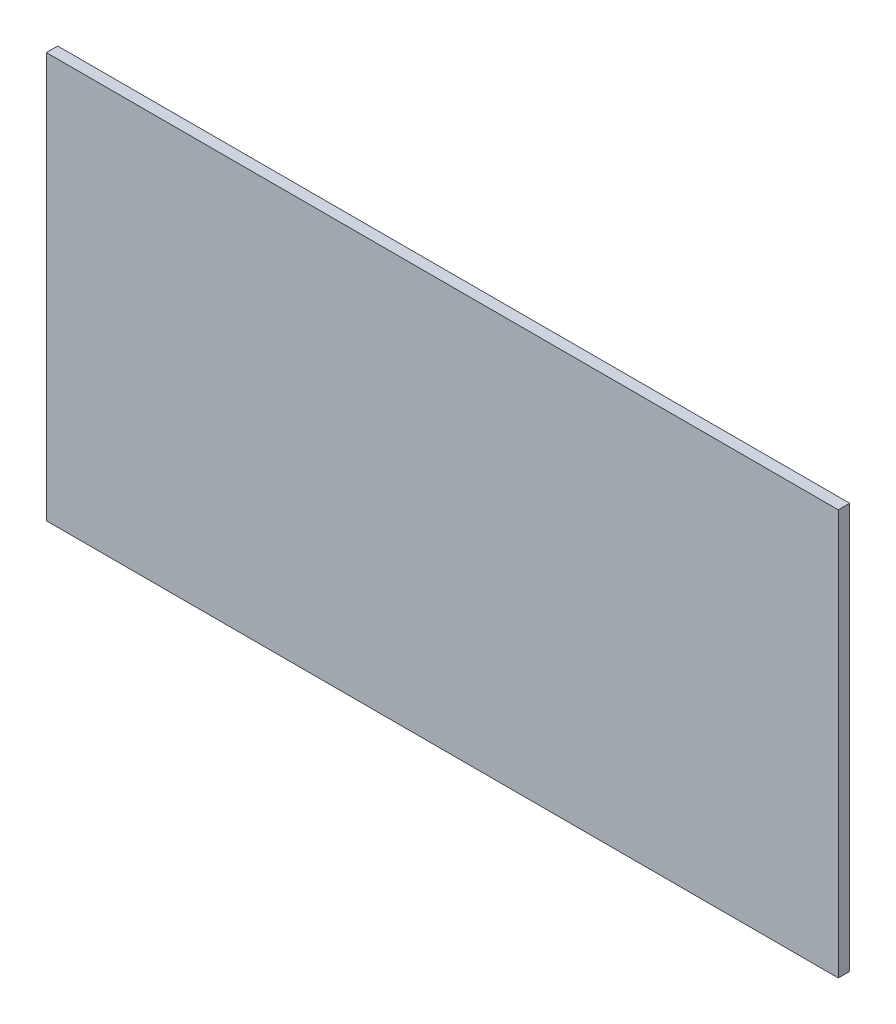
from build123d import *

# Parameters (mm, degrees)
SKETCH1_W           = 209
SKETCH1_H           = 107
BOSS_EXTRUDE1_DEPTH = 3


with BuildPart() as part:
    # Sketch1 → Boss-Extrude1 (new body)
    with BuildSketch(Plane.XY):
        Rectangle(SKETCH1_W, SKETCH1_H)
    extrude(amount=BOSS_EXTRUDE1_DEPTH)


solid = part.part
